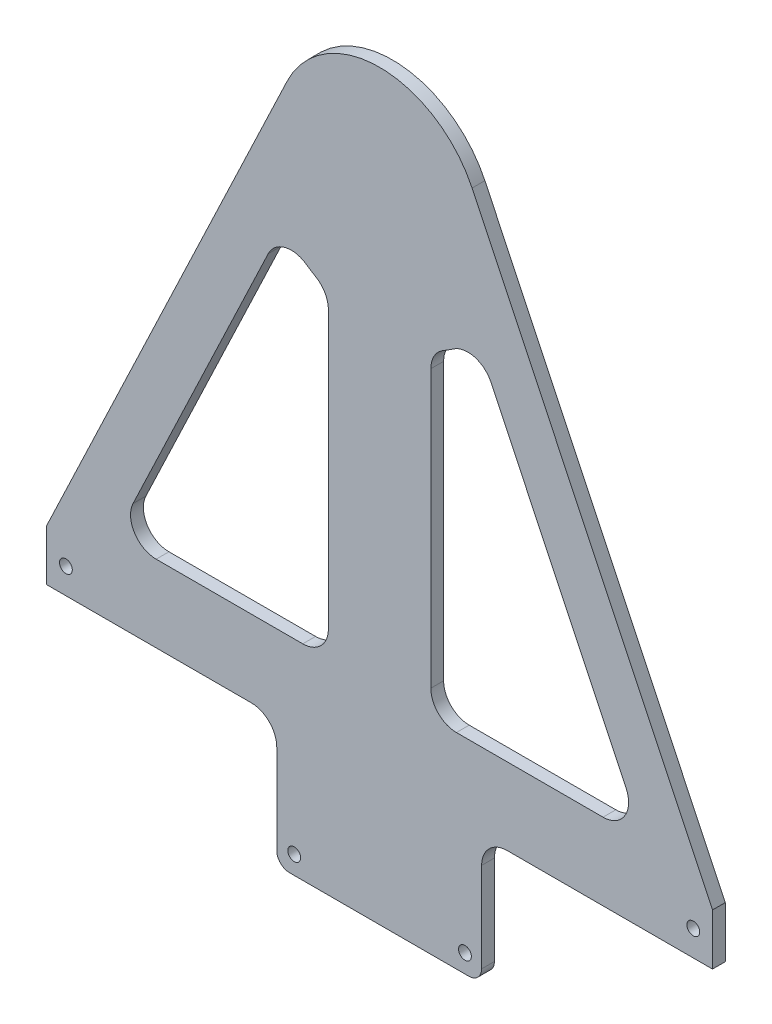
from build123d import *

# Parameters (mm, degrees)
SKETCH5_R           = 1.5875
BOSS_EXTRUDE2_DEPTH = 3.175


with BuildPart() as part:
    # Sketch5 → Boss-Extrude2 (new body)
    with BuildSketch(Plane.XY):
        with BuildLine():
            Line((-82.55, 58.42), (-82.55, 45.72))
            Line((-82.55, 45.72), (-31.848963051, 45.72))
            ThreePointArc((-31.848963051, 45.72), (-27.35883499, 43.860128061), (-25.498963051, 39.37))
            Line((-25.498963051, 39.37), (-25.498963051, 17.145))
            ThreePointArc((-25.498963051, 17.145), (-24.569027081, 14.89993597), (-22.323963051, 13.97))
            Line((-22.323963051, 13.97), (22.126036949, 13.97))
            ThreePointArc((22.126036949, 13.97), (24.37110098, 14.89993597), (25.301036949, 17.145))
            Line((25.301036949, 17.145), (25.301036949, 39.37))
            ThreePointArc((25.301036949, 39.37), (27.160908889, 43.860128061), (31.651036949, 45.72))
            Line((31.651036949, 45.72), (82.55, 45.72))
            Line((82.55, 45.72), (82.55, 58.42))
            Line((82.55, 58.42), (22.933465972, 183.638614313))
            ThreePointArc((22.933465972, 183.638614313), (0, 198.12), (-22.933465972, 183.638614313))
            Line((-22.933465972, 183.638614313), (-82.55, 58.42))
        make_face()
        with Locations((21.166666667, 18.525000034)):
            Circle(SKETCH5_R, mode=Mode.SUBTRACT)
        with Locations((-21.166666667, 18.525000034)):
            Circle(SKETCH5_R, mode=Mode.SUBTRACT)
        with Locations((-77.7875, 52.07)):
            Circle(SKETCH5_R, mode=Mode.SUBTRACT)
        with Locations((77.7875, 52.07)):
            Circle(SKETCH5_R, mode=Mode.SUBTRACT)
        with BuildLine():
            Line((-61.138040857, 73.849653578), (-27.615581335, 144.260253558))
            ThreePointArc((-27.615581335, 144.260253558), (-23.498279642, 147.671514779), (-18.235179035, 146.728833317))
            ThreePointArc((-18.235179035, 146.728833317), (-17.071685329, 145.950239821), (-15.875, 145.22369343))
            ThreePointArc((-15.875, 145.22369343), (-13.550738686, 142.899432116), (-12.7, 139.724432116))
            Line((-12.7, 139.724432116), (-12.7, 71.12))
            ThreePointArc((-12.7, 71.12), (-14.559871939, 66.629871939), (-19.05, 64.77))
            Line((-19.05, 64.77), (-55.404674364, 64.77))
            ThreePointArc((-55.404674364, 64.77), (-60.77383632, 67.729631305), (-61.138040857, 73.849653578))
        make_face(mode=Mode.SUBTRACT)
        with BuildLine():
            Line((61.138040857, 73.849653578), (27.615581335, 144.260253558))
            ThreePointArc((27.615581335, 144.260253558), (23.498279642, 147.671514779), (18.235179035, 146.728833317))
            ThreePointArc((18.235179035, 146.728833317), (17.071685329, 145.950239821), (15.875, 145.22369343))
            ThreePointArc((15.875, 145.22369343), (13.550738686, 142.899432116), (12.7, 139.724432116))
            Line((12.7, 139.724432116), (12.7, 71.12))
            ThreePointArc((12.7, 71.12), (14.559871939, 66.629871939), (19.05, 64.77))
            Line((19.05, 64.77), (55.404674364, 64.77))
            ThreePointArc((55.404674364, 64.77), (60.77383632, 67.729631305), (61.138040857, 73.849653578))
        make_face(mode=Mode.SUBTRACT)
    extrude(amount=BOSS_EXTRUDE2_DEPTH)


solid = part.part
